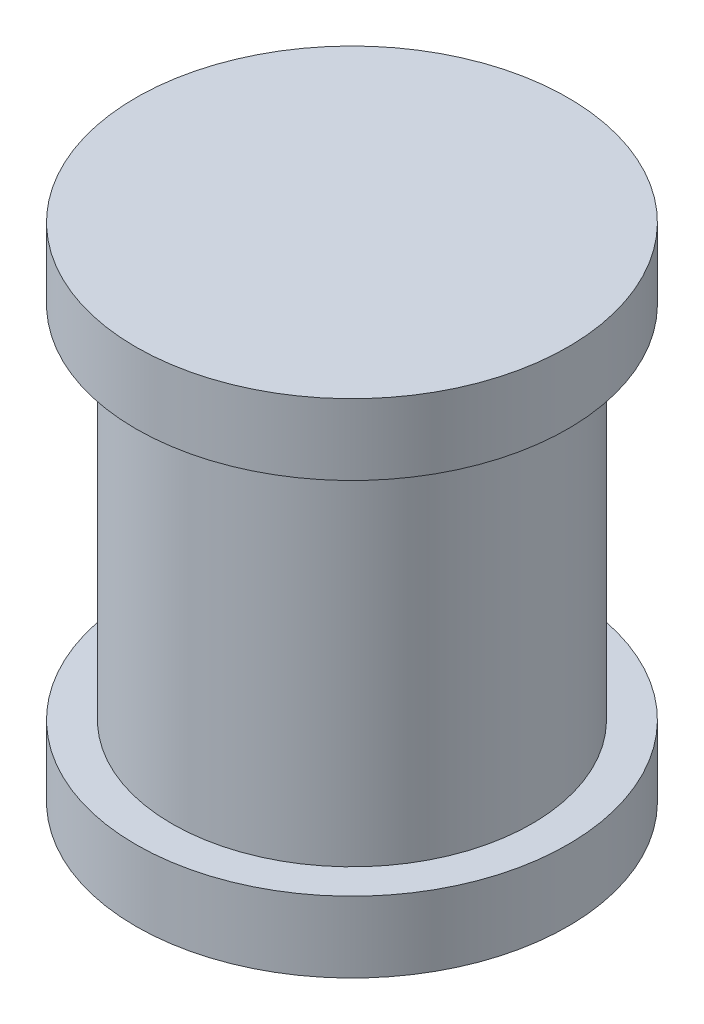
from build123d import *

# Parameters (mm, degrees)
SKETCH1_R           = 12.7
BOSS_EXTRUDE1_DEPTH = 12.7
SKETCH2_R           = 15.24
BOSS_EXTRUDE2_DEPTH = 5


with BuildPart() as part:
    # Sketch1 → Boss-Extrude1 (new body, symmetric)
    with BuildSketch(Plane(origin=(0, 0, 0), x_dir=(1, 0, 0), z_dir=(0, 1, 0))):
        Circle(SKETCH1_R)
    extrude(amount=BOSS_EXTRUDE1_DEPTH, both=True)

    # Sketch2 → Boss-Extrude2 (add)
    with BuildSketch(Plane(origin=(0, 12.7, 0), x_dir=(1, 0, 0), z_dir=(0, 1, 0))):
        Circle(SKETCH2_R)
    boss_extrude2 = extrude(amount=BOSS_EXTRUDE2_DEPTH)

    # Mirror1: Boss-Extrude2 across plane
    add(boss_extrude2.mirror(Plane.ZX))


solid = part.part
